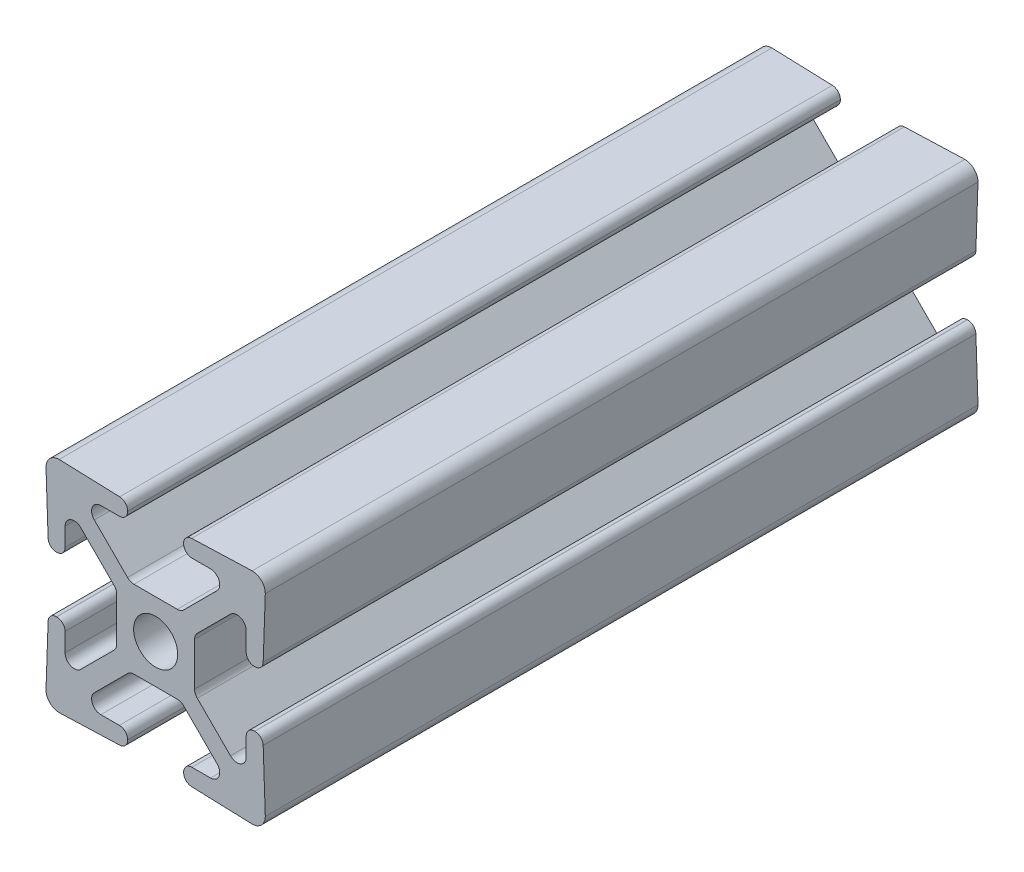
from build123d import *

# Parameters (mm, degrees)
SKETCH1_R      = 2.5527
EXTRUDE1_DEPTH = 82.55


with BuildPart() as part:
    # Sketch1 → Extrude1 (new body)
    with BuildSketch(Plane.XY):
        with BuildLine():
            Line((3.238504286, -11.455400345), (3.238504286, -11.49073383))
            ThreePointArc((3.238504286, -11.49073383), (3.509397472, -12.161218003), (4.170019162, -12.455345741))
            Line((4.170019162, -12.455345741), (11.176001705, -12.7))
            ThreePointArc((11.176001705, -12.7), (12.253632411, -12.253630746), (12.700001664, -11.17600004))
            Line((12.700001664, -11.17600004), (12.455347406, -4.170014669))
            ThreePointArc((12.455347406, -4.170014669), (12.16121968, -3.509392954), (11.490735494, -3.238499755))
            Line((11.490735494, -3.238499755), (11.455402009, -3.238499755))
            ThreePointArc((11.455402009, -3.238499755), (10.772902626, -3.521200256), (10.490202125, -4.20369964))
            Line((10.490202125, -4.20369964), (10.490202125, -6.352134987))
            ThreePointArc((10.490202125, -6.352134987), (9.831646779, -7.337732713), (8.669054992, -7.106478829))
            Line((8.669054992, -7.106478829), (4.820959759, -3.258383596))
            ThreePointArc((4.820959759, -3.258383596), (4.589705874, -2.912287699), (4.508500309, -2.504039754))
            Line((4.508500309, -2.504039754), (4.508500309, 2.504040946))
            ThreePointArc((4.508500309, 2.504040946), (4.589705874, 2.912288891), (4.820959759, 3.258384788))
            Line((4.820959759, 3.258384788), (8.669054992, 7.106480021))
            ThreePointArc((8.669054992, 7.106480021), (9.831646779, 7.337733906), (10.490202125, 6.35213618))
            Line((10.490202125, 6.35213618), (10.490202125, 4.203700832))
            ThreePointArc((10.490202125, 4.203700832), (10.772902626, 3.521201448), (11.455402009, 3.238500947))
            Line((11.455402009, 3.238500947), (11.490735494, 3.238500947))
            ThreePointArc((11.490735494, 3.238500947), (12.161219667, 3.509394133), (12.455347406, 4.170015823))
            Line((12.455347406, 4.170015823), (12.700001664, 11.176000039))
            ThreePointArc((12.700001664, 11.176000039), (12.253632411, 12.253630745), (11.176001705, 12.699999999))
            Line((11.176001705, 12.699999999), (4.170019162, 12.455345462))
            ThreePointArc((4.170019162, 12.455345462), (3.509397447, 12.161217736), (3.238504248, 11.49073355))
            Line((3.238504248, 11.49073355), (3.238504248, 11.455400065))
            ThreePointArc((3.238504248, 11.455400065), (3.521204749, 10.772900682), (4.203704132, 10.490200181))
            Line((4.203704132, 10.490200181), (6.35213948, 10.490200181))
            ThreePointArc((6.35213948, 10.490200181), (7.337737205, 9.831644835), (7.106483322, 8.669053049))
            Line((7.106483322, 8.669053049), (3.258388088, 4.820957816))
            ThreePointArc((3.258388088, 4.820957816), (2.912292192, 4.589703931), (2.504044247, 4.508498366))
            Line((2.504044247, 4.508498366), (-2.504036453, 4.508498366))
            ThreePointArc((-2.504036453, 4.508498366), (-2.912284398, 4.589703931), (-3.258380295, 4.820957816))
            Line((-3.258380295, 4.820957816), (-7.106475528, 8.669053049))
            ThreePointArc((-7.106475528, 8.669053049), (-7.337729412, 9.831644836), (-6.352131686, 10.490200182))
            Line((-6.352131686, 10.490200182), (-4.203696339, 10.490200182))
            ThreePointArc((-4.203696339, 10.490200182), (-3.521196955, 10.772900683), (-3.238496454, 11.455400067))
            Line((-3.238496454, 11.455400067), (-3.238496454, 11.490733551))
            ThreePointArc((-3.238496454, 11.490733551), (-3.50938964, 12.161217724), (-4.17001133, 12.455345462))
            Line((-4.17001133, 12.455345462), (-11.175998375, 12.699999999))
            ThreePointArc((-11.175998375, 12.699999999), (-12.253629081, 12.253630745), (-12.699998335, 11.176000039))
            Line((-12.699998335, 11.176000039), (-12.455343798, 4.170015823))
            ThreePointArc((-12.455343798, 4.170015823), (-12.161216073, 3.509394108), (-11.490731887, 3.238500909))
            Line((-11.490731887, 3.238500909), (-11.455398403, 3.238500909))
            ThreePointArc((-11.455398403, 3.238500909), (-10.772899019, 3.52120141), (-10.490198518, 4.203700793))
            Line((-10.490198518, 4.203700793), (-10.490198518, 6.352136141))
            ThreePointArc((-10.490198518, 6.352136141), (-9.831643172, 7.337733867), (-8.669051385, 7.106479983))
            Line((-8.669051385, 7.106479983), (-4.820956152, 3.258384749))
            ThreePointArc((-4.820956152, 3.258384749), (-4.589702267, 2.912288853), (-4.508496702, 2.504040908))
            Line((-4.508496702, 2.504040908), (-4.508496702, -2.504039793))
            ThreePointArc((-4.508496702, -2.504039793), (-4.589702267, -2.912287738), (-4.820956152, -3.258383634))
            Line((-4.820956152, -3.258383634), (-8.669051385, -7.106478867))
            ThreePointArc((-8.669051385, -7.106478867), (-9.831643172, -7.337732752), (-10.490198518, -6.352135026))
            Line((-10.490198518, -6.352135026), (-10.490198518, -4.203699678))
            ThreePointArc((-10.490198518, -4.203699678), (-10.772899019, -3.521200294), (-11.455398403, -3.238499793))
            Line((-11.455398403, -3.238499793), (-11.490731887, -3.238499793))
            ThreePointArc((-11.490731887, -3.238499793), (-12.16121606, -3.509392979), (-12.455343798, -4.170014669))
            Line((-12.455343798, -4.170014669), (-12.699998335, -11.17600004))
            ThreePointArc((-12.699998335, -11.17600004), (-12.253629081, -12.253630746), (-11.175998375, -12.7))
            Line((-11.175998375, -12.7), (-4.17001133, -12.455345741))
            ThreePointArc((-4.17001133, -12.455345741), (-3.509389615, -12.161218016), (-3.238496416, -11.49073383))
            Line((-3.238496416, -11.49073383), (-3.238496416, -11.455400345))
            ThreePointArc((-3.238496416, -11.455400345), (-3.521196917, -10.772900961), (-4.2036963, -10.49020046))
            Line((-4.2036963, -10.49020046), (-6.352131648, -10.49020046))
            ThreePointArc((-6.352131648, -10.49020046), (-7.337729374, -9.831645114), (-7.106475489, -8.669053328))
            Line((-7.106475489, -8.669053328), (-3.258380256, -4.820958094))
            ThreePointArc((-3.258380256, -4.820958094), (-2.91228436, -4.58970421), (-2.504036415, -4.508498645))
            Line((-2.504036415, -4.508498645), (2.504044285, -4.508498645))
            ThreePointArc((2.504044285, -4.508498645), (2.91229223, -4.58970421), (3.258388127, -4.820958094))
            Line((3.258388127, -4.820958094), (7.10648336, -8.669053328))
            ThreePointArc((7.10648336, -8.669053328), (7.337737245, -9.831645114), (6.352139519, -10.49020046))
            Line((6.352139519, -10.49020046), (4.203704171, -10.49020046))
            ThreePointArc((4.203704171, -10.49020046), (3.521204787, -10.772900961), (3.238504286, -11.455400345))
        make_face()
        Circle(SKETCH1_R, mode=Mode.SUBTRACT)
    extrude(amount=EXTRUDE1_DEPTH)


solid = part.part
